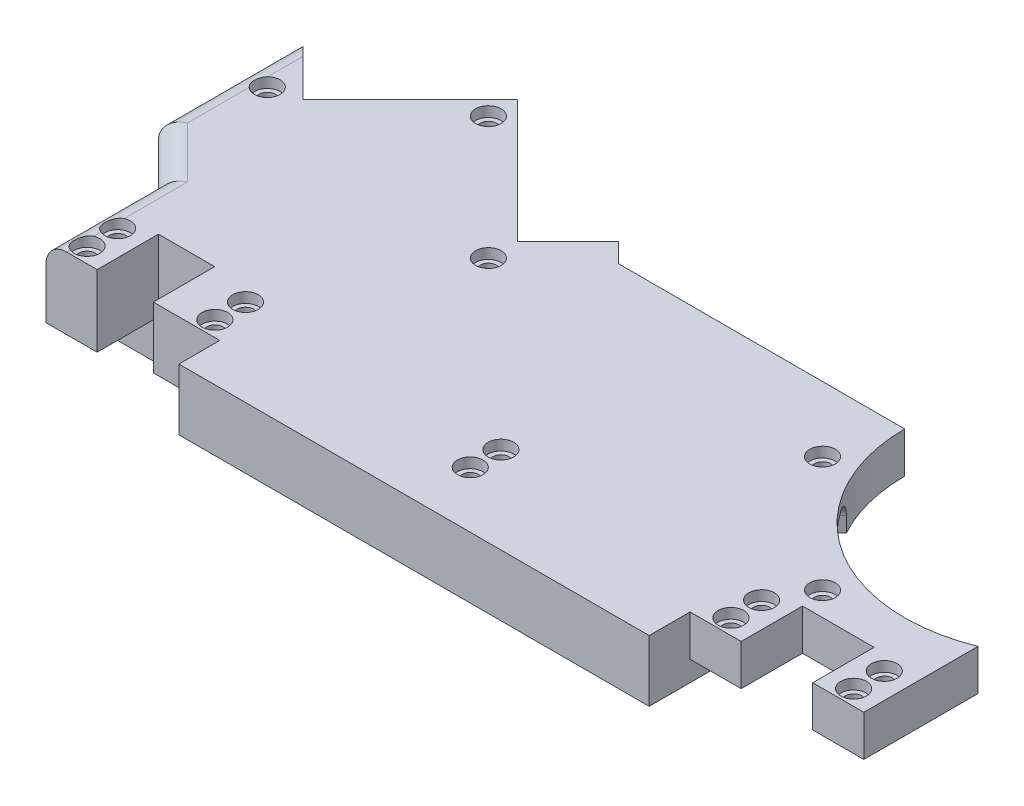
from build123d import *

# Parameters (mm, degrees)
BOSS_EXTRUDE1_DEPTH      = 11
BOSS_EXTRUDE2_START      = 11
BOSS_EXTRUDE2_DEPTH      = 1
BOSS_EXTRUDE3_START      = 11
SKETCH5_W                = 5
SKETCH5_H                = 6
SKETCH5_W_2              = 6.5
BOSS_EXTRUDE3_DEPTH      = 7
SKETCH9_R                = 2.25
BOSS_EXTRUDE4_DEPTH      = 3
BOSS_EXTRUDE5_DEPTH      = 5
SKETCH7_R                = 1.75
TUBE_HOLES_DEPTH         = 4
PALM_TUBE_OPENING_DEPTH  = 10
WRIST_TUBE_OPENING_DEPTH = 5
SKETCH13_W               = 5
SKETCH13_H               = 6
SKETCH13_W_2             = 6.5
SKETCH13_H_2             = 7
CUT_EXTRUDE1_DEPTH       = 4
FILLET1_R                = 2
POT_INSERT_DEPTH         = 2.5
SCREW_START              = 12
SKETCH6_R                = 0.8
SCREW_HOLES_DEPTH        = 18
SKETCH10_R               = 1.25
SCREW_HEADS_DEPTH        = 2
CUT_EXTRUDE2_DEPTH       = 7
CUT_EXTRUDE4_DEPTH       = 7


with BuildPart() as part:
    # Sketch1 → Boss-Extrude1 (new body)
    with BuildSketch(Plane(origin=(0, 0, 0), x_dir=(1, 0, 0), z_dir=(0, 1, 0))):
        with BuildLine():
            Line((24.994192305, 10.517747211), (0.994192305, 10.517747211))
            Line((0.994192305, 10.517747211), (-0.899142434, 12.41108195))
            Line((-0.899142434, 12.41108195), (-5.848889902, 7.461334481))
            Line((-5.848889902, 7.461334481), (-17.86980821, 19.482252789))
            Line((-17.86980821, 19.482252789), (-28.348953445, 9.003107554))
            Line((-28.348953445, 9.003107554), (-34.005807695, 14.659961804))
            Line((-34.005807695, 14.659961804), (-34.005807695, 0.517747211))
            Line((-34.005807695, 0.517747211), (-29.005807695, -4.482252789))
            Line((-29.005807695, -4.482252789), (-29.005807695, -9.482252789))
            Line((-29.005807695, -9.482252789), (-12.005807695, -9.482252789))
            Line((-12.005807695, -9.482252789), (-12.005807695, -19.482252789))
            Line((-12.005807695, -19.482252789), (33.994192305, -19.482252789))
            Line((33.994192305, -19.482252789), (33.994192305, -15.482252791))
            Line((33.994192305, -15.482252791), (38.994192305, -15.482252791))
            Line((38.994192305, -15.482252791), (38.994192305, -9.482252791))
            Line((38.994192305, -9.482252791), (45.994192305, -9.482252791))
            Line((45.994192305, -9.482252791), (45.994192305, -15.482252791))
            Line((45.994192305, -15.482252791), (50.994192304, -15.482252791))
            Line((50.994192304, -15.482252791), (50.994192304, -4.314649764))
            ThreePointArc((50.994192304, -4.314649764), (36.049920395, -2.74875195), (28.994192305, 10.517747211))
            Line((28.994192305, 10.517747211), (24.994192305, 10.517747211))
        make_face()
        Polygon((13.494192305, -16.482252789), (32.994192305, -16.482252789), (32.994192305, -8.592903632), (24.994192305, -0.592903632), (24.994192305, 9.517747211), (1.864171021, 9.517747211), (-5.84899293, 1.80458326), (-19.991128553, 15.946718883), (-33.005807695, 2.932039742), (-33.005807695, 0.931960773), (-28.005807695, -4.068039227), (-28.005807695, -8.482252789), (-11.005807695, -8.482252789), (-11.005807695, -16.482252789), (8.494192305, -16.482252789), (8.494192305, -9.482252792), (13.494192305, -9.482252792), align=None, mode=Mode.SUBTRACT)
    extrude(amount=BOSS_EXTRUDE1_DEPTH)

    # Sketch3 → Boss-Extrude2 (add)
    with BuildSketch(Plane(origin=(0, 0, 0), x_dir=(1, 0, 0), z_dir=(0, 1, 0)).offset(BOSS_EXTRUDE2_START)):
        with BuildLine():
            Line((-17.86980821, 19.482252789), (-5.848889902, 7.461334481))
            Line((-5.848889902, 7.461334481), (-0.899142434, 12.41108195))
            Line((-0.899142434, 12.41108195), (0.994192305, 10.517747211))
            Line((0.994192305, 10.517747211), (24.994192305, 10.517747211))
            Line((24.994192305, 10.517747211), (28.994192305, 10.517747211))
            ThreePointArc((28.994192305, 10.517747211), (36.049920395, -2.74875195), (50.994192304, -4.314649764))
            Line((50.994192304, -4.314649764), (50.994192304, -15.482252791))
            Line((50.994192304, -15.482252791), (45.994192305, -15.482252791))
            Line((45.994192305, -15.482252791), (45.994192305, -9.482252791))
            Line((45.994192305, -9.482252791), (38.994192305, -9.482252791))
            Line((38.994192305, -9.482252791), (38.994192305, -15.482252791))
            Line((38.994192305, -15.482252791), (33.994192305, -15.482252791))
            Line((33.994192305, -15.482252791), (33.994192305, -19.482252789))
            Line((33.994192305, -19.482252789), (-12.005807695, -19.482252789))
            Line((-12.005807695, -19.482252789), (-12.005807695, -9.482252789))
            Line((-12.005807695, -9.482252789), (-29.005807695, -9.482252789))
            Line((-29.005807695, -9.482252789), (-29.005807695, -4.482252789))
            Line((-29.005807695, -4.482252789), (-34.005807695, 0.517747211))
            Line((-34.005807695, 0.517747211), (-34.005807695, 14.659961804))
            Line((-34.005807695, 14.659961804), (-28.348953445, 9.003107554))
            Line((-28.348953445, 9.003107554), (-17.86980821, 19.482252789))
        make_face()
    extrude(amount=-BOSS_EXTRUDE2_DEPTH)

    # Sketch5 → Boss-Extrude3 (add)
    with BuildSketch(Plane(origin=(0, 0, 0), x_dir=(1, 0, 0), z_dir=(0, 1, 0)).offset(BOSS_EXTRUDE3_START)):
        with Locations((-26.505807695, -12.482252789)):
            Rectangle(SKETCH5_W, SKETCH5_H)
        with Locations((-15.255807695, -12.482252789)):
            Rectangle(SKETCH5_W_2, SKETCH5_H)
    extrude(amount=-BOSS_EXTRUDE3_DEPTH)

    # Sketch9 → Boss-Extrude4 (add)
    with BuildSketch(Plane(origin=(0.80622229, 0, -0.80622229), x_dir=(-0.707106781, 0, -0.707106781), z_dir=(0.707106781, 0, -0.707106781))):
        with Locations((20.911895624, 0)):
            Circle(SKETCH9_R)
    extrude(amount=BOSS_EXTRUDE4_DEPTH)

    # Sketch11 → Boss-Extrude5 (add)
    with BuildSketch(Plane(origin=(0, 0, 0), x_dir=(1, 0, 0), z_dir=(0, 1, 0))):
        Polygon((-17.86980821, 19.482252789), (-20.698235335, 16.653825665), (-5.84899293, 1.80458326), (1.929181663, 9.582757853), (-0.899142434, 12.41108195), (-5.848889902, 7.461334481), align=None)
    extrude(amount=-BOSS_EXTRUDE5_DEPTH)

    # Sketch7 → Tube Holes (cut)
    with BuildSketch(Plane(origin=(-6.655112192, 0, -6.655112192), x_dir=(-0.707106781, 0, 0.707106781), z_dir=(-0.707106781, 0, -0.707106781))):
        with Locations((-4.640170496, 2)):
            Circle(SKETCH7_R)
        with Locations((-4.640170496, -2)):
            Circle(SKETCH7_R)
    extrude(amount=-TUBE_HOLES_DEPTH, mode=Mode.SUBTRACT)

    # Sketch8 → Palm Tube Opening (cut)
    with BuildSketch(Plane(origin=(0, 0, 0), x_dir=(1, 0, 0), z_dir=(0, 1, 0))):
        Polygon((24.994192305, 10.517747211), (0.994192305, 10.517747211), (1.929181663, 9.582757853), (1.864171021, 9.517747211), (27.864171021, -16.482252789), (32.994192305, -16.482252789), (32.994192305, -10.369554414), (28.931746465, -14.432000255), (20.044444837, -5.544698627), (24.994192305, -0.594951158), align=None)
        Polygon((-28.348953445, 9.003107554), (-20.698235335, 16.653825665), (-19.991128553, 15.946718883), (-27.641846664, 8.296000773), align=None)
    extrude(amount=PALM_TUBE_OPENING_DEPTH, mode=Mode.SUBTRACT)

    # Sketch12 → Wrist Tube Opening (cut)
    with BuildSketch(Plane(origin=(0, 0, 0), x_dir=(1, 0, 0), z_dir=(0, 1, 0))):
        Polygon((33.994192305, -19.482252789), (33.994192305, -9.592903632), (32.883541462, -8.482252789), (-12.005807695, -8.482252789), (-12.005807695, -19.482252789), align=None)
    extrude(amount=WRIST_TUBE_OPENING_DEPTH, mode=Mode.SUBTRACT)

    # Sketch13 → Cut-Extrude1 (cut)
    with BuildSketch(Plane(origin=(0, 0, 0), x_dir=(1, 0, 0), z_dir=(0, 1, 0))):
        with Locations((-26.505807695, -12.482252789)):
            Rectangle(SKETCH13_W, SKETCH13_H)
        with Locations((-15.255807695, -11.982252789)):
            Rectangle(SKETCH13_W_2, SKETCH13_H_2)
    extrude(amount=CUT_EXTRUDE1_DEPTH, mode=Mode.SUBTRACT)

    # Fillet1
    fillet1_edges = [part.edges().sort_by_distance(p)[0] for p in [
        (-34.005807695, 11, -7.588854507),
        (-31.505807695, 11, 1.982252789),
        (-29.005807695, 11, 9.982252789),
    ]]
    fillet(fillet1_edges, radius=FILLET1_R)

    # Sketch14 → Pot Insert (cut)
    with BuildSketch(Plane.ZY.offset(18.505807695)):
        Polygon((24.976594858, 1), (23.476594858, 4), (23.476594858, 5), (19.476594858, 5), (14.226594858, 5), (14.226594858, 4), (8.476594858, 4), (8.476594858, -0.5), (8.476594858, -5), (14.226594858, -5), (14.226594858, -6), (19.476594858, -6), (23.476594858, -6), (23.476594858, -5), (24.976594858, -2), (24.976594858, -0.5), align=None)
    extrude(amount=-POT_INSERT_DEPTH, mode=Mode.SUBTRACT)

    # Sketch6 → Screw Holes (cut, through all)
    with BuildSketch(Plane(origin=(0, 0, 0), x_dir=(1, 0, 0), z_dir=(0, 1, 0)).offset(SCREW_START)):
        with Locations((-31.141846664, 8.296000773)):
            Circle(SKETCH6_R)
        with Locations((-26.500149763, -10.976594858)):
            Circle(SKETCH6_R)
        with Locations((-26.500149763, -13.976594858)):
            Circle(SKETCH6_R)
        with Locations((-14.000149763, -13.976594858)):
            Circle(SKETCH6_R)
        with Locations((-14.000149763, -10.976594858)):
            Circle(SKETCH6_R)
        with Locations((10.994192305, -10.982252789)):
            Circle(SKETCH6_R)
        with Locations((10.994192305, -13.982252789)):
            Circle(SKETCH6_R)
        with Locations((-17.86980821, 16.653825665)):
            Circle(SKETCH6_R)
        with Locations((-5.84899293, 4.633010384)):
            Circle(SKETCH6_R)
        with Locations((27.316522776, 4.15378618)):
            Circle(SKETCH6_R)
        with Locations((38.630231275, -7.159922319)):
            Circle(SKETCH6_R)
        with Locations((36.494192305, -13.982252789)):
            Circle(SKETCH6_R)
        with Locations((36.494192305, -10.982252789)):
            Circle(SKETCH6_R)
        with Locations((48.494192305, -10.982252789)):
            Circle(SKETCH6_R)
        with Locations((48.494192305, -13.982252789)):
            Circle(SKETCH6_R)
    extrude(amount=-SCREW_HOLES_DEPTH, mode=Mode.SUBTRACT)

    # Sketch10 → Screw Heads (cut)
    with BuildSketch(Plane(origin=(0, 0, 0), x_dir=(1, 0, 0), z_dir=(0, 1, 0)).offset(SCREW_START)):
        with Locations((-17.86980821, 16.653825665)):
            Circle(SKETCH10_R)
        with Locations((-31.141846664, 8.296000773)):
            Circle(SKETCH10_R)
        with Locations((-26.500149763, -10.976594858)):
            Circle(SKETCH10_R)
        with Locations((-26.500149763, -13.976594858)):
            Circle(SKETCH10_R)
        with Locations((-14.000149763, -13.976594858)):
            Circle(SKETCH10_R)
        with Locations((-14.000149763, -10.976594858)):
            Circle(SKETCH10_R)
        with Locations((10.994192305, -10.982252789)):
            Circle(SKETCH10_R)
        with Locations((10.994192305, -13.982252789)):
            Circle(SKETCH10_R)
        with Locations((-5.84899293, 4.633010384)):
            Circle(SKETCH10_R)
        with Locations((27.316522776, 4.15378618)):
            Circle(SKETCH10_R)
        with Locations((38.630231275, -7.159922319)):
            Circle(SKETCH10_R)
        with Locations((36.494192305, -10.982252789)):
            Circle(SKETCH10_R)
        with Locations((36.494192305, -13.982252789)):
            Circle(SKETCH10_R)
        with Locations((48.494192305, -10.982252789)):
            Circle(SKETCH10_R)
        with Locations((48.494192305, -13.982252789)):
            Circle(SKETCH10_R)
    extrude(amount=-SCREW_HEADS_DEPTH, mode=Mode.SUBTRACT)

    # Sketch15 → Cut-Extrude2 (cut)
    with BuildSketch(Plane(origin=(0, 0, 0), x_dir=(1, 0, 0), z_dir=(0, 1, 0))):
        with BuildLine():
            Line((24.994192305, -0.592903632), (24.994192305, 10.517747211))
            Line((24.994192305, 10.517747211), (28.994192305, 10.517747211))
            ThreePointArc((28.994192305, 10.517747211), (36.049920395, -2.74875195), (50.994192304, -4.314649764))
            Line((50.994192304, -4.314649764), (50.994192304, -15.482252791))
            Line((50.994192304, -15.482252791), (45.994192305, -15.482252791))
            Line((45.994192305, -15.482252791), (45.994192305, -9.482252791))
            Line((45.994192305, -9.482252791), (38.994192305, -9.482252791))
            Line((38.994192305, -9.482252791), (38.994192305, -15.482252791))
            Line((38.994192305, -15.482252791), (33.994192305, -15.482252791))
            Line((33.994192305, -15.482252791), (33.994192305, -9.592903632))
            Line((33.994192305, -9.592903632), (24.994192305, -0.592903632))
        make_face()
    extrude(amount=CUT_EXTRUDE2_DEPTH, mode=Mode.SUBTRACT)

    # Sketch19 → Cut-Extrude4 (cut)
    with BuildSketch(Plane(origin=(12.200644337, 0, -12.200644337), x_dir=(0.707106781, 0, 0.707106781), z_dir=(-0.707106781, 0, 0.707106781))):
        with BuildLine():
            Line((19.878528118, 8.5), (19.878528118, 7))
            Line((19.878528118, 7), (28.878528118, 7))
            Line((28.878528118, 7), (28.878528118, 8.5))
            ThreePointArc((28.878528118, 8.5), (28.43918829, 9.560660172), (27.378528118, 10))
            Line((27.378528118, 10), (21.378528118, 10))
            ThreePointArc((21.378528118, 10), (20.317867946, 9.560660172), (19.878528118, 8.5))
        make_face()
    extrude(amount=-CUT_EXTRUDE4_DEPTH, mode=Mode.SUBTRACT)


solid = part.part
